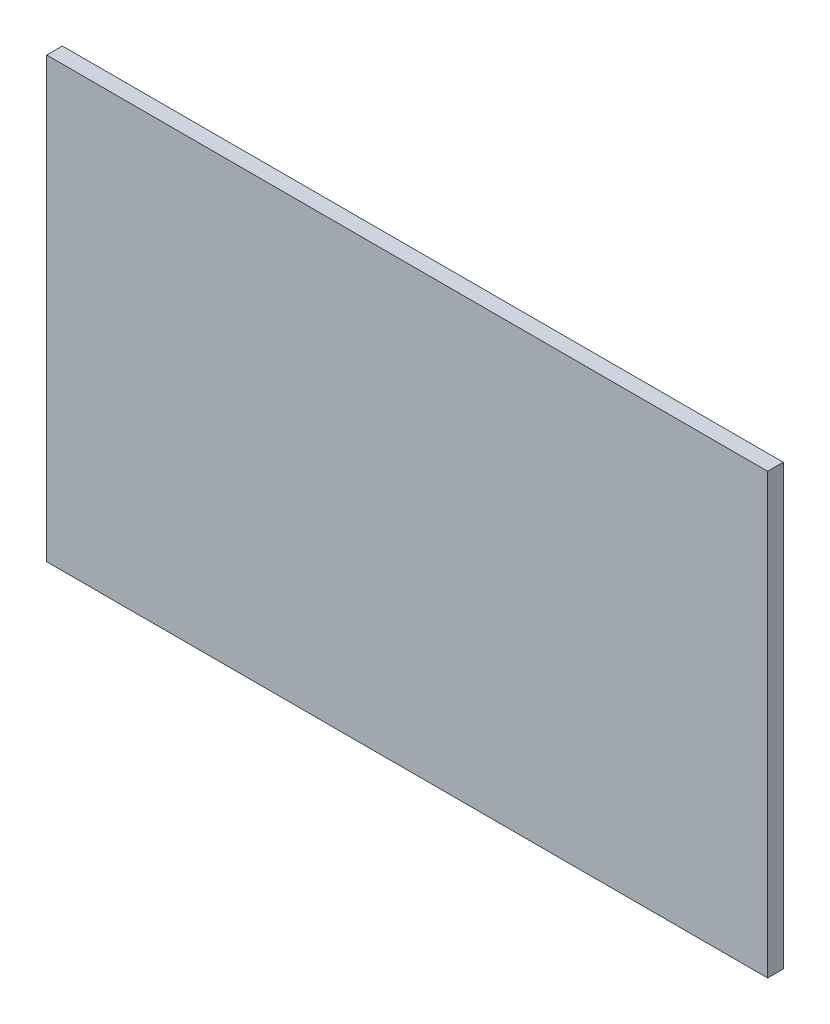
from build123d import *

# Parameters (mm, degrees)
SKETCH1_W           = 230
SKETCH1_H           = 140
BOSS_EXTRUDE1_DEPTH = 5


with BuildPart() as part:
    # Sketch1 → Boss-Extrude1 (new body)
    with BuildSketch(Plane.XY):
        Rectangle(SKETCH1_W, SKETCH1_H)
    extrude(amount=BOSS_EXTRUDE1_DEPTH)


solid = part.part
